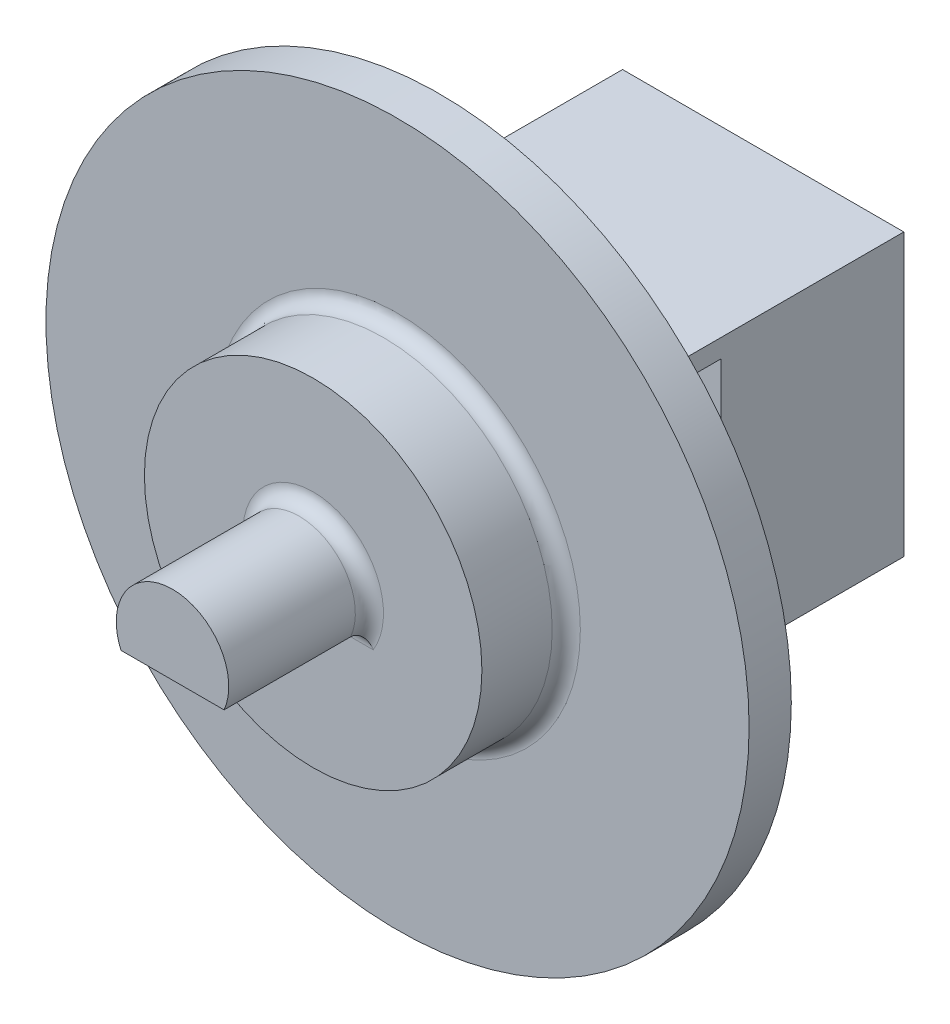
from build123d import *

# Parameters (mm, degrees)
SKETCH3_W           = 10
SKETCH3_H           = 10
SKETCH3_R           = 1.75
BOSS_EXTRUDE4_DEPTH = 11.5
CUT_EXTRUDE1_START  = 11.5
CUT_EXTRUDE1_DEPTH  = 5
SKETCH4_R           = 12.5
BOSS_EXTRUDE5_DEPTH = 1.5
SKETCH5_W           = 5
SKETCH5_H           = 5.8
CUT_EXTRUDE2_DEPTH  = 14.634995112
SKETCH6_R           = 6
BOSS_EXTRUDE6_DEPTH = 3
FILLET1_R           = 0.5
FILLET2_R           = 0.5
BOSS_EXTRUDE7_DEPTH = 5
FILLET3_R           = 0.5


with BuildPart() as part:
    # Sketch3 → Boss-Extrude4 (new body)
    with BuildSketch(Plane.XY):
        Rectangle(SKETCH3_W, SKETCH3_H)
        Circle(SKETCH3_R, mode=Mode.SUBTRACT)
    extrude(amount=BOSS_EXTRUDE4_DEPTH)

    # Sketch3_3 → Cut-Extrude1 (cut)
    with BuildSketch(Plane.XY.offset(CUT_EXTRUDE1_START)):
        Polygon((3.234529708, 0.866689623), (0.866689623, 3.234529708), (-2.367840085, 2.367840085), (-3.234529708, -0.866689623), (-0.866689623, -3.234529708), (2.367840085, -2.367840085), align=None)
    extrude(amount=-CUT_EXTRUDE1_DEPTH, mode=Mode.SUBTRACT)

    # Sketch4 → Boss-Extrude5 (add)
    with BuildSketch(Plane.XY.offset(11.5)):
        Circle(SKETCH4_R)
        Polygon((3.234529708, 0.866689623), (0.866689623, 3.234529708), (-2.367840085, 2.367840085), (-3.234529708, -0.866689623), (-0.866689623, -3.234529708), (2.367840085, -2.367840085), align=None, mode=Mode.SUBTRACT)
    extrude(amount=BOSS_EXTRUDE5_DEPTH)

    # Sketch5 → Cut-Extrude2 (cut, through all)
    with BuildSketch(Plane(origin=(2.92867424, -4.460901648, 0), x_dir=(0, 0, 1), z_dir=(0.965925826, 0.258819045, 0))):
        with Locations((9, -5.066896781)):
            Rectangle(SKETCH5_W, SKETCH5_H)
    extrude(amount=CUT_EXTRUDE2_DEPTH, mode=Mode.SUBTRACT)

    # Sketch6 → Boss-Extrude6 (add)
    with BuildSketch(Plane.XY.offset(13)):
        Circle(SKETCH6_R)
    extrude(amount=BOSS_EXTRUDE6_DEPTH)

    # Fillet1
    fillet1_edges = [part.edges().sort_by_distance(p)[0] for p in [
        (-0.750575231, 2.801184896, 13),
        (-2.801184896, 0.750575231, 13),
        (-2.050609665, -2.050609665, 13),
        (0.750575231, -2.801184896, 13),
    ]]
    fillet(fillet1_edges, radius=FILLET1_R)

    # Fillet2
    fillet2_edges = [part.edges().sort_by_distance(p)[0] for p in [
        (-6, 0, 13),
    ]]
    fillet(fillet2_edges, radius=FILLET2_R)

    # Sketch7 → Boss-Extrude7 (add)
    with BuildSketch(Plane.XY.offset(16)):
        with BuildLine():
            Line((-1.833030278, -0.8), (1.833030278, -0.8))
            ThreePointArc((1.833030278, -0.8), (0, 2), (-1.833030278, -0.8))
        make_face()
    extrude(amount=BOSS_EXTRUDE7_DEPTH)

    # Fillet3
    fillet3_edges = [part.edges().sort_by_distance(p)[0] for p in [
        (0, 2, 16),
        (0, -0.8, 16),
    ]]
    fillet(fillet3_edges, radius=FILLET3_R)


solid = part.part
